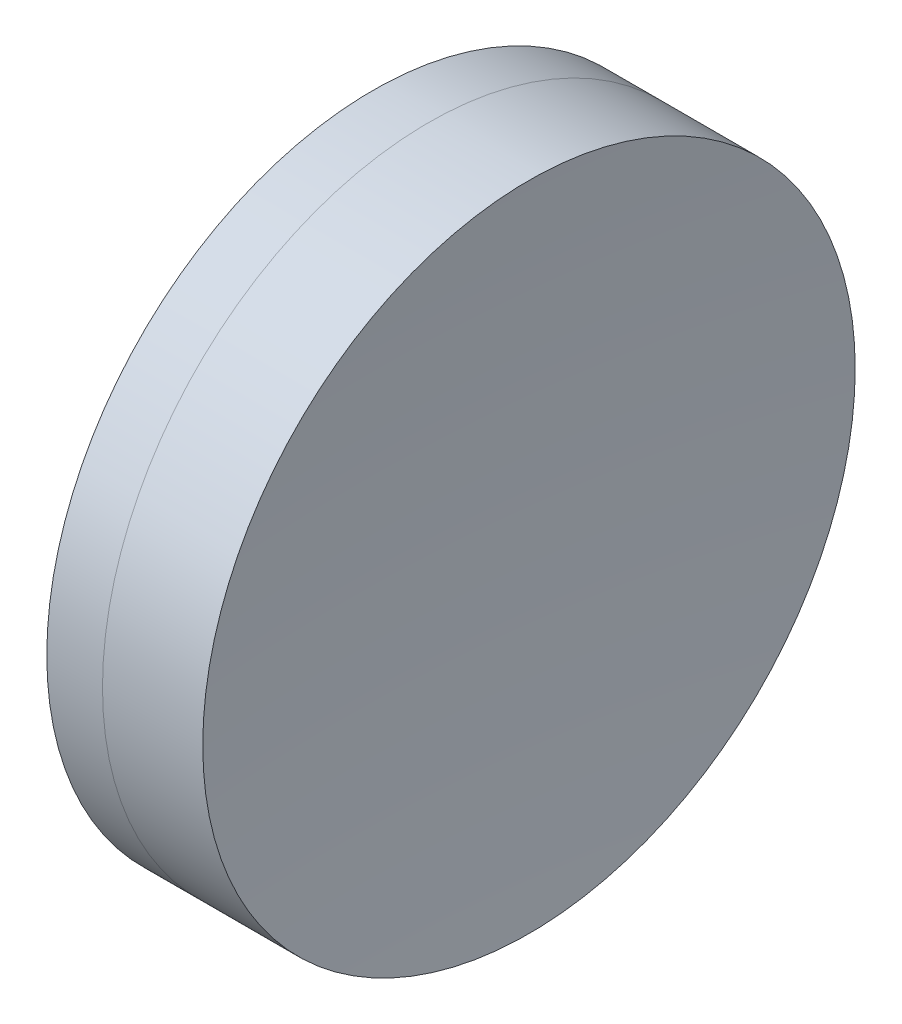
from build123d import *


with BuildPart() as part:
    # 草图1 one side → 旋转1 (revolve)
    with BuildSketch(Plane(origin=(0, 0, 0), x_dir=(1, 0, 0), z_dir=(0, 1, 0)), mode=Mode.PRIVATE) as revolve_1_sk:
        with BuildLine():
            ThreePointArc((85.403453721, 12.7), (84.532775295, 6.376511056), (84.241742486, 0))
            Line((84.241742486, 0), (88.441742486, 0))
            ThreePointArc((88.441742486, 0), (88.223939635, 6.364888744), (87.571550053, 12.7))
            Line((87.571550053, 12.7), (85.403453721, 12.7))
        make_face()
    revolve(revolve_1_sk.sketch.rotate(Axis((-0.816062176, 0, 0), (1, 0, 0)), 180), axis=Axis((-0.816062176, 0, 0), (1, 0, 0)))  # turned: the seam where the file's is


with BuildPart() as body_2:
    # 草图2 one side → 旋转2 (revolve)
    with BuildSketch(Plane(origin=(0, 0, 0), x_dir=(1, 0, 0), z_dir=(0, 1, 0)), mode=Mode.PRIVATE) as revolve_2_sk:
        with BuildLine():
            Line((91.475486151, 12.7), (87.571550053, 12.7))
            ThreePointArc((87.571550053, 12.7), (88.223939635, 6.364888744), (88.441742486, 0))
            Line((88.441742486, 0), (90.941742486, 0))
            ThreePointArc((90.941742486, 0), (91.075237271, 6.355605445), (91.475486151, 12.7))
        make_face()
    revolve(revolve_2_sk.sketch.rotate(Axis((-0.551919993, 0, 0), (1, 0, 0)), 180), axis=Axis((-0.551919993, 0, 0), (1, 0, 0)))  # turned: the seam where the file's is


solid = Compound([part.part, body_2.part])
